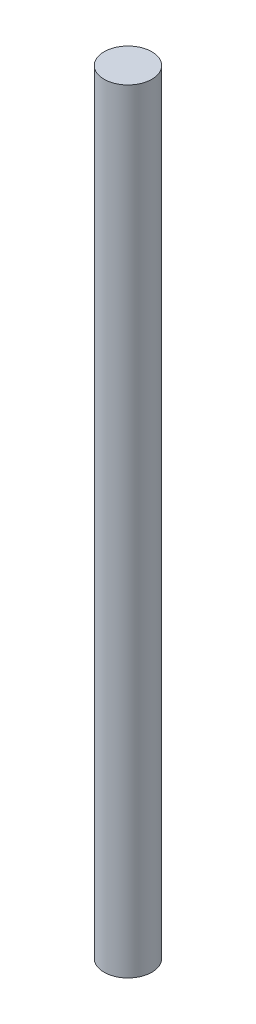
from build123d import *

# Parameters (mm, degrees)
SKETCH2_R           = 5.55625
BOSS_EXTRUDE1_DEPTH = 180


with BuildPart() as part:
    # Sketch2 → Boss-Extrude1 (new body)
    with BuildSketch(Plane(origin=(0, 0, 0), x_dir=(1, 0, 0), z_dir=(0, 1, 0))):
        Circle(SKETCH2_R)
    extrude(amount=BOSS_EXTRUDE1_DEPTH)


solid = part.part
